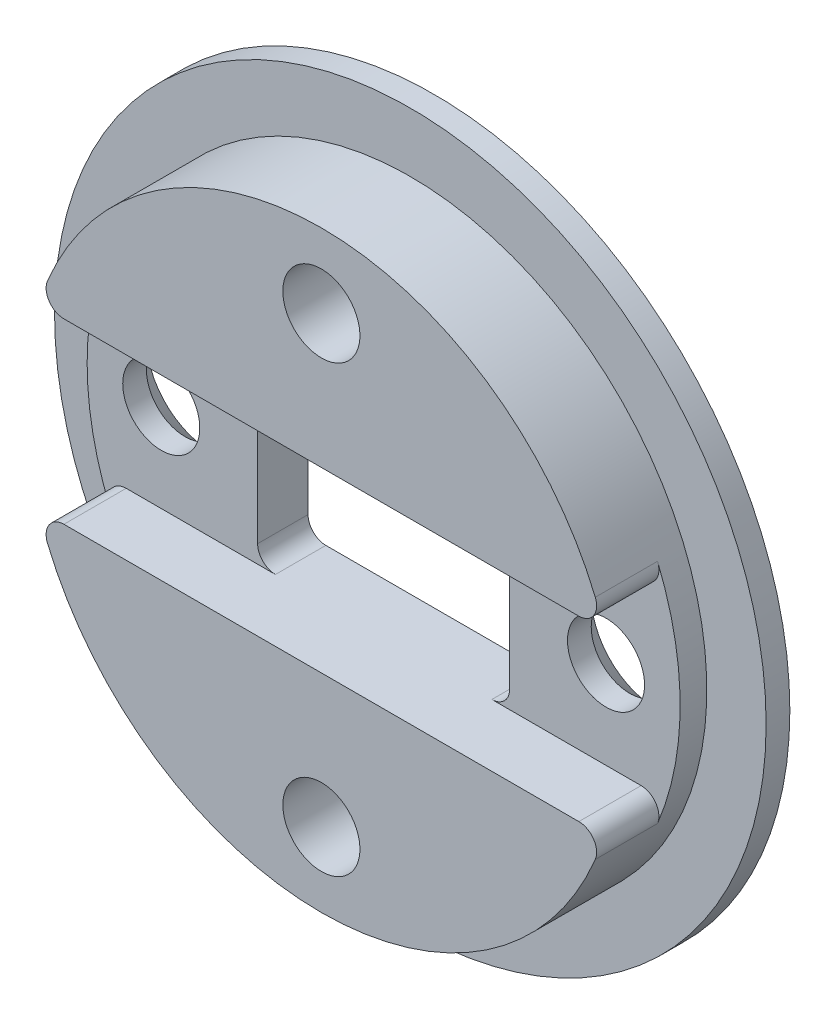
from build123d import *

# Parameters (mm, degrees)
SKIZZE14_W                                           = 8.5
SKIZZE14_H                                           = 6
SCHNITT_LINEAR_AUSTRAGEN4_DEPTH                      = 4.8
SKIZZE15_W                                           = 24
SKIZZE15_H                                           = 6
SCHNITT_LINEAR_AUSTRAGEN5_DEPTH                      = 2.1
VERRUNDUNG1_R                                        = 0.6
VERRUNDUNG2_R                                        = 0.6
FORMSENKUNG_F_R_M2_LINSENSENKSCHRAUBE_MI_D           = 2.6
FORMSENKUNG_F_R_M2_LINSENSENKSCHRAUBE_MI_CSINK_D     = 4.4
FORMSENKUNG_F_R_M2_LINSENSENKSCHRAUBE_MI_CSINK_ANGLE = 90
FORMSENKUNG_F_R_M2_LINSENSENKSCHRAUB_2_D             = 2.6
FORMSENKUNG_F_R_M2_LINSENSENKSCHRAUB_2_CSINK_D       = 4.4
FORMSENKUNG_F_R_M2_LINSENSENKSCHRAUB_2_CSINK_ANGLE   = 90


with BuildPart() as part:
    # Skizze2 → Rotation1 (revolve)
    with BuildSketch(Plane(origin=(0, 0, 0), x_dir=(1, 0, 0), z_dir=(0, 1, 0))):
        Polygon((0, 0), (10, 0), (10, 3), (12, 3), (12, 3.8), (0, 3.8), align=None)
    revolve(axis=Axis((0, 0, -3.8), (0, 0, 1)))

    # Skizze14 → Schnitt-Linear austragen4 (cut, through all)
    with BuildSketch(Plane.XY):
        Rectangle(SKIZZE14_W, SKIZZE14_H)
    extrude(amount=-SCHNITT_LINEAR_AUSTRAGEN4_DEPTH, mode=Mode.SUBTRACT)

    # Skizze15 → Schnitt-Linear austragen5 (cut)
    with BuildSketch(Plane.XY):
        Rectangle(SKIZZE15_W, SKIZZE15_H)
    extrude(amount=-SCHNITT_LINEAR_AUSTRAGEN5_DEPTH, mode=Mode.SUBTRACT)

    # Verrundung1
    verrundung1_edges = [part.edges().sort_by_distance(p)[0] for p in [
        (4.25, 3, -2.95),
        (4.25, -3, -2.95),
        (-4.25, -3, -2.95),
        (-4.25, 3, -2.95),
    ]]
    fillet(verrundung1_edges, radius=VERRUNDUNG1_R)

    # Verrundung2
    verrundung2_edges = [part.edges().sort_by_distance(p)[0] for p in [
        (-9.539392014, -3, -1.05),
        (9.539392014, -3, -1.05),
        (9.539392014, 3, -1.05),
        (-9.539392014, 3, -1.05),
    ]]
    fillet(verrundung2_edges, radius=VERRUNDUNG2_R)

    # Formsenkung f_r M2 Linsensenkschraube mi (through all)
    with Locations(Plane(origin=(0, 0, -3.8), x_dir=(1, 0, 0), z_dir=(0, 0, -1))):
        with Locations((-7.5, 0), (7.5, 0)):
            CounterSinkHole(FORMSENKUNG_F_R_M2_LINSENSENKSCHRAUBE_MI_D / 2, FORMSENKUNG_F_R_M2_LINSENSENKSCHRAUBE_MI_CSINK_D / 2, counter_sink_angle=FORMSENKUNG_F_R_M2_LINSENSENKSCHRAUBE_MI_CSINK_ANGLE)

    # Formsenkung f_r M2 Linsensenkschraub 2 (through all)
    with Locations(Plane(origin=(0, 0, -3.8), x_dir=(-1, 0, 0), z_dir=(0, 0, -1))):
        with Locations((0, 7.5), (0, -7.5)):
            CounterSinkHole(FORMSENKUNG_F_R_M2_LINSENSENKSCHRAUB_2_D / 2, FORMSENKUNG_F_R_M2_LINSENSENKSCHRAUB_2_CSINK_D / 2, counter_sink_angle=FORMSENKUNG_F_R_M2_LINSENSENKSCHRAUB_2_CSINK_ANGLE)


solid = part.part
